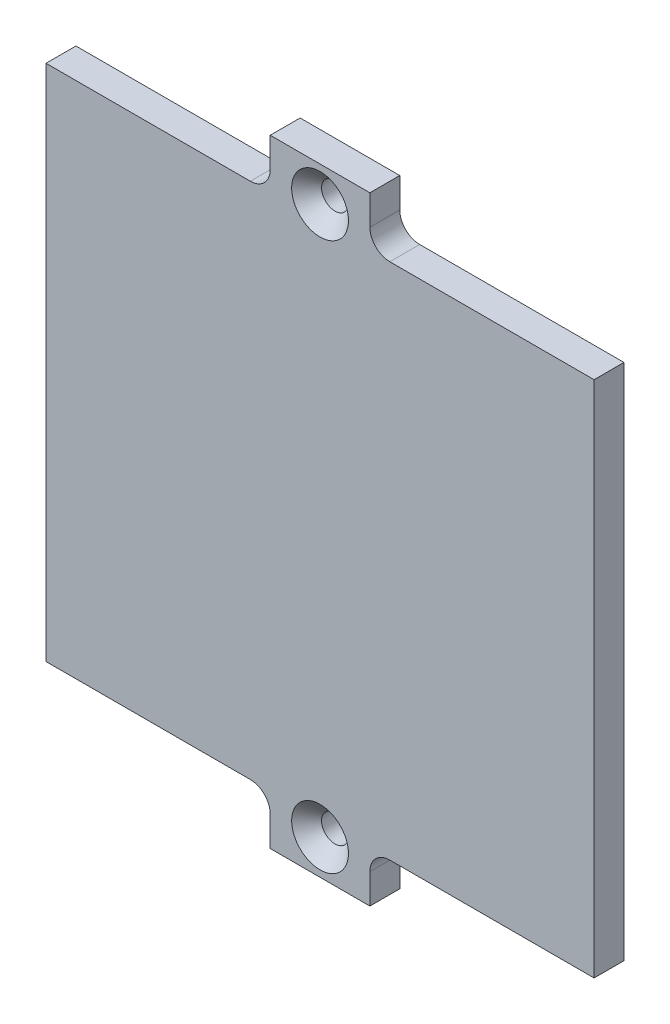
from build123d import *

# Parameters (mm, degrees)
SKETCH_1_R      = 1.35
EXTRUDE_1_DEPTH = 3
CHAMFER_1_SIZE  = 1.5


with BuildPart() as part:
    # Эскиз1 → Бобышка-Вытянуть1 (new body)
    with BuildSketch(Plane.XY):
        with BuildLine():
            Line((68.8, 25.85), (48.3, 25.85))
            ThreePointArc((48.3, 25.85), (46.885786438, 26.435786438), (46.3, 27.85))
            Line((46.3, 27.85), (46.3, 30.84491535))
            Line((46.3, 30.84491535), (36.3, 30.84491535))
            Line((36.3, 30.84491535), (36.3, 27.85))
            ThreePointArc((36.3, 27.85), (35.714213562, 26.435786438), (34.3, 25.85))
            Line((34.3, 25.85), (13.8, 25.85))
            Line((13.8, 25.85), (13.8, -26.15))
            Line((13.8, -26.15), (34.3, -26.15))
            ThreePointArc((34.3, -26.15), (35.714213562, -26.735786438), (36.3, -28.15))
            Line((36.3, -28.15), (36.3, -31.15))
            Line((36.3, -31.15), (46.3, -31.15))
            Line((46.3, -31.15), (46.3, -28.15))
            ThreePointArc((46.3, -28.15), (46.885786438, -26.735786438), (48.3, -26.15))
            Line((48.3, -26.15), (68.8, -26.15))
            Line((68.8, -26.15), (68.8, 25.85))
        make_face()
        with Locations((41.3, 27.347457675)):
            Circle(SKETCH_1_R, mode=Mode.SUBTRACT)
        with Locations((41.3, -27.652542325)):
            Circle(SKETCH_1_R, mode=Mode.SUBTRACT)
    extrude(amount=EXTRUDE_1_DEPTH)

    # Фаска1
    chamfer_1_edges = [part.edges().sort_by_distance(p)[0] for p in [
        (39.95, -27.652542325, 3),
        (39.95, 27.347457675, 3),
    ]]
    chamfer(chamfer_1_edges, length=CHAMFER_1_SIZE)


solid = part.part
